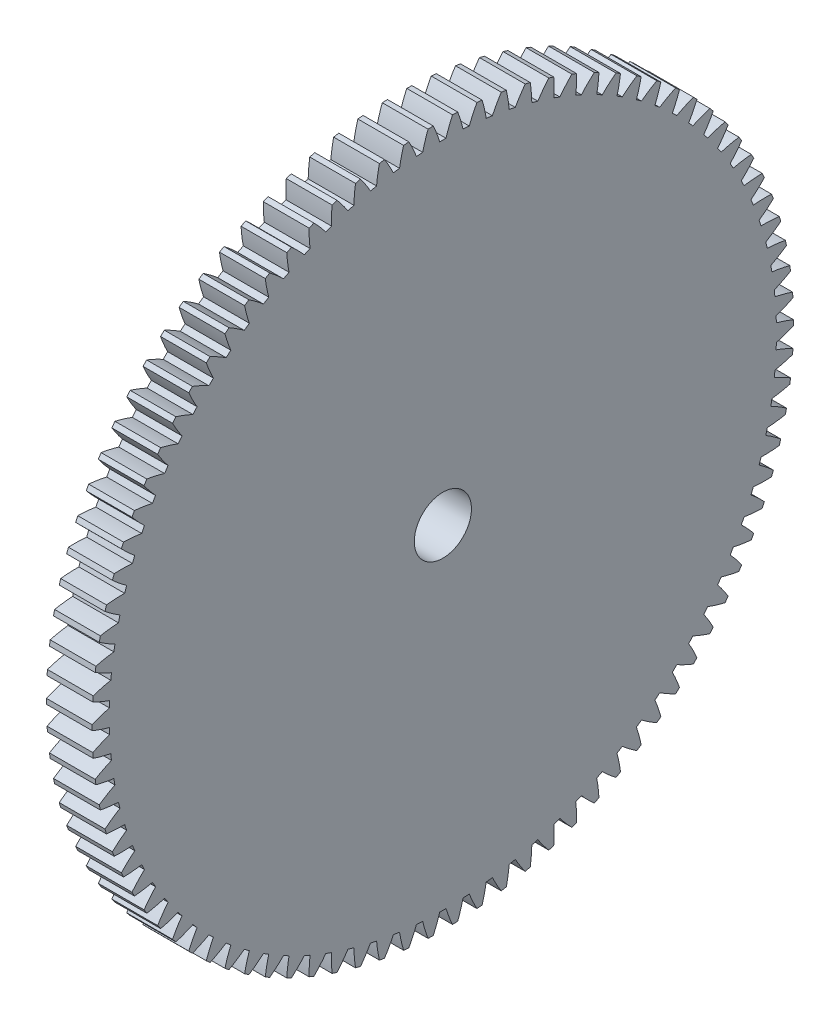
from build123d import *

# Parameters (mm, degrees)
BASPROSKE_W     = 12
BASPROSKE_H     = 92
TOOTHCUT_DEPTH  = 131.659863768
TEETHCUTS_COUNT = 90
TEETHCUTS_ANGLE = 356
BORSKE_R        = 7.5
BORE_DEPTH      = 50.0000508


with BuildPart() as part:
    # BasProSke → Base-Revolve (revolve)
    with BuildSketch(Plane(origin=(0, 0, 0), x_dir=(1, 0, 0), z_dir=(0, 1, 0)), mode=Mode.PRIVATE) as base_revolve_sk:
        with Locations((6, 46)):
            Rectangle(BASPROSKE_W, BASPROSKE_H)
    revolve(base_revolve_sk.sketch.rotate(Axis((-10, 0, 0), (1, 0, 0)), 180), axis=Axis((-10, 0, 0), (1, 0, 0)))

    # TooCutSke → ToothCut (cut, through all)
    with BuildSketch(Plane(origin=(0, 0, 0), x_dir=(0, 0, -1), z_dir=(1, 0, 0))):
        with BuildLine():
            ThreePointArc((0.819599755, 87.495161336), (0, 87.499), (-0.819599755, 87.495161336))
            ThreePointArc((-0.819599755, 87.495161336), (-1.60570744, 89.771545798), (-2.542254478, 91.990277678))
            ThreePointArc((-2.542254478, 91.990277678), (0, 92.0254), (2.542254478, 91.990277678))
            ThreePointArc((2.542254478, 91.990277678), (1.60570744, 89.771545798), (0.819599755, 87.495161336))
        make_face()
    toothcut = extrude(amount=TOOTHCUT_DEPTH, mode=Mode.SUBTRACT)

    # TeethCuts: ToothCut ×90 about axis
    teethcuts_axis = Axis((-10, 0, 0), (1, 0, 0))
    for i in range(1, TEETHCUTS_COUNT):
        add(toothcut.rotate(teethcuts_axis, i * TEETHCUTS_ANGLE / (TEETHCUTS_COUNT - 1)), mode=Mode.SUBTRACT)

    # BorSke → Bore (cut, symmetric)
    with BuildSketch(Plane(origin=(0, 0, 0), x_dir=(0, 0, -1), z_dir=(1, 0, 0))):
        with Locations(Location((0, 0, 0), (0, 0, 180))):
            Circle(BORSKE_R)
    extrude(amount=BORE_DEPTH, both=True, mode=Mode.SUBTRACT)


solid = part.part
